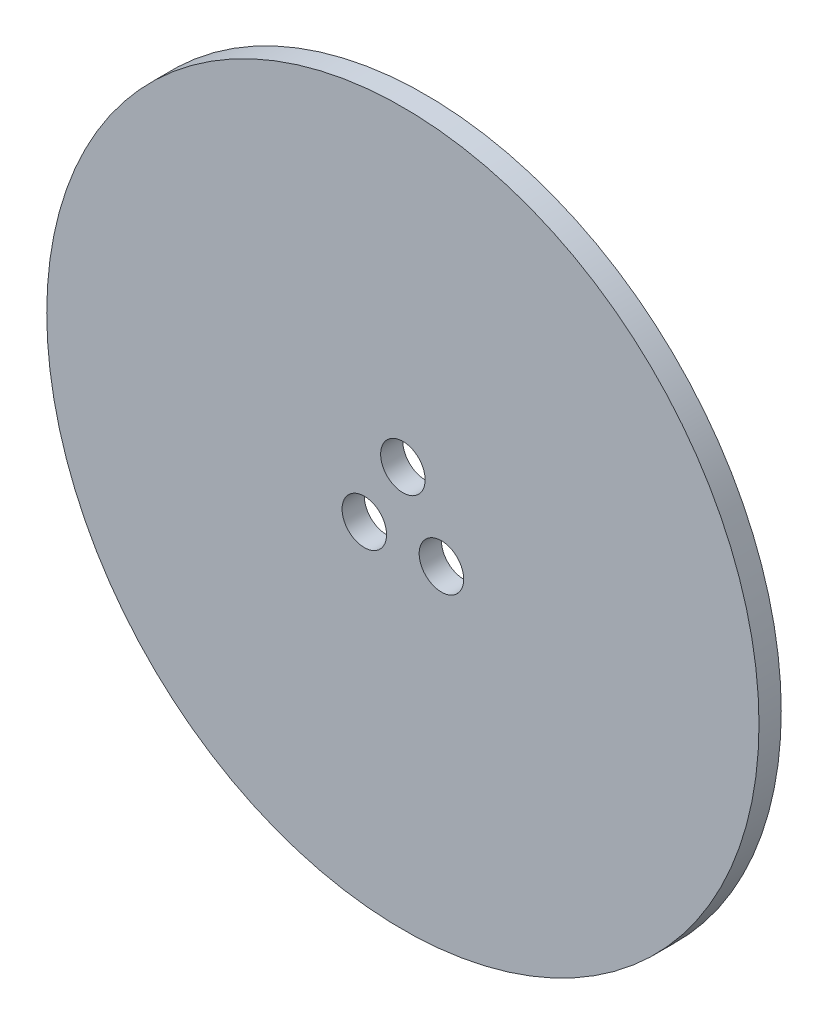
from build123d import *

# Parameters (mm, degrees)
SKETCH1_R           = 50.8
BOSS_EXTRUDE1_DEPTH = 3.175
SKETCH2_R           = 3.175
CUT_EXTRUDE1_DEPTH  = 3.175


with BuildPart() as part:
    # Sketch1 → Boss-Extrude1 (new body)
    with BuildSketch(Plane.XY):
        Circle(SKETCH1_R)
    extrude(amount=BOSS_EXTRUDE1_DEPTH)

    # Sketch2 → Cut-Extrude1 (cut)
    with BuildSketch(Plane.XY.offset(3.175)):
        with Locations((0, 6.35)):
            Circle(SKETCH2_R)
        with Locations((5.499261314, -3.175)):
            Circle(SKETCH2_R)
        with Locations((-5.499261314, -3.175)):
            Circle(SKETCH2_R)
    extrude(amount=-CUT_EXTRUDE1_DEPTH, mode=Mode.SUBTRACT)


solid = part.part
